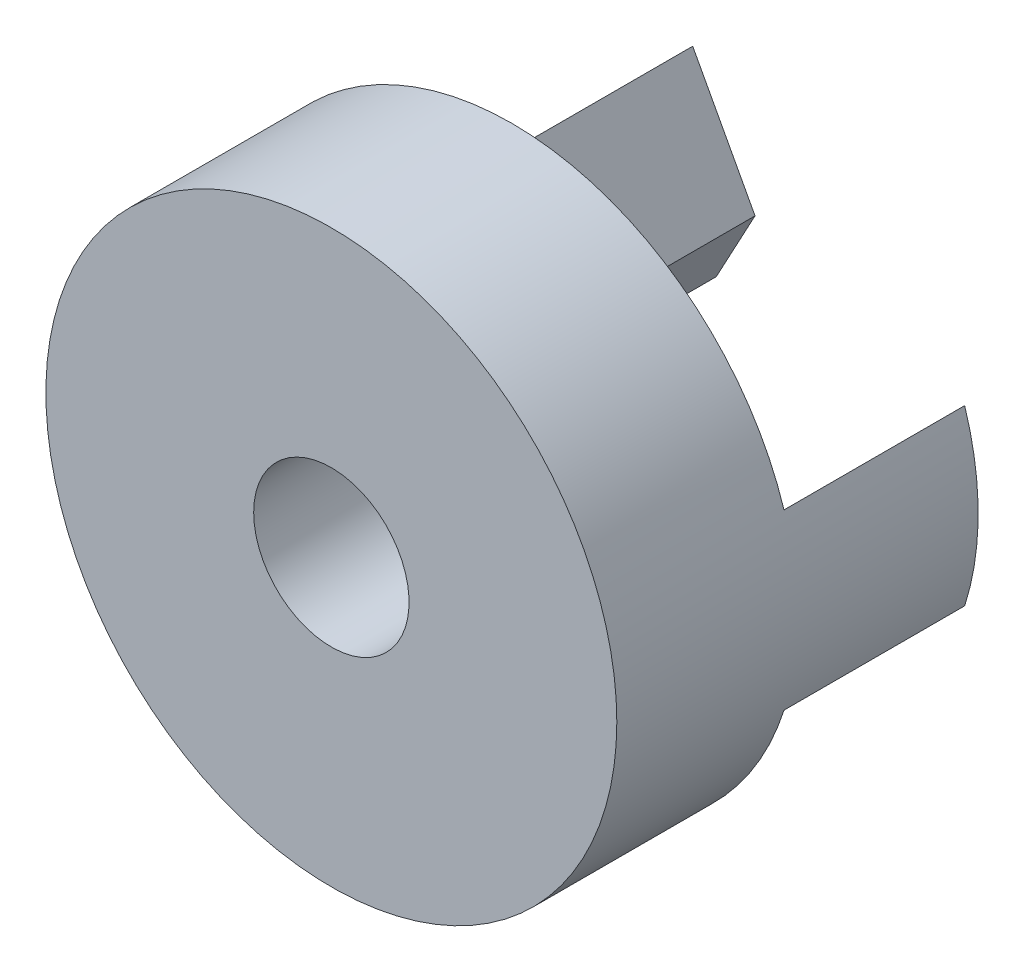
from build123d import *

# Parameters (mm, degrees)
SKETCH1_R           = 20.066
BOSS_EXTRUDE1_DEPTH = 12.7
SKETCH2_R           = 5.461
CUT_EXTRUDE1_DEPTH  = 13.7
BOSS_EXTRUDE2_DEPTH = 12.7


with BuildPart() as part:
    # Sketch1 → Boss-Extrude1 (new body)
    with BuildSketch(Plane.XY):
        Circle(SKETCH1_R)
    extrude(amount=BOSS_EXTRUDE1_DEPTH)

    # Sketch2 → Cut-Extrude1 (cut, through all)
    with BuildSketch(Plane(origin=(0, 0, 0), x_dir=(-1, 0, 0), z_dir=(0, 0, -1))):
        Circle(SKETCH2_R)
    extrude(amount=-CUT_EXTRUDE1_DEPTH, mode=Mode.SUBTRACT)

    # Sketch3 → Boss-Extrude2 (add)
    with BuildSketch(Plane(origin=(0, 0, 0), x_dir=(-1, 0, 0), z_dir=(0, 0, -1))):
        with BuildLine():
            Line((-19.117613345, -6.096), (-14.9225, 0))
            Line((-14.9225, 0), (-19.117613345, 6.096))
            ThreePointArc((-19.117613345, 6.096), (-20.066, 0), (-19.117613345, -6.096))
        make_face()
        with BuildLine():
            Line((19.117613345, 6.096), (14.9225, 0))
            Line((14.9225, 0), (19.117613345, -6.096))
            ThreePointArc((19.117613345, -6.096), (20.066, 0), (19.117613345, 6.096))
        make_face()
        with BuildLine():
            Line((0, 18.415), (-4.3815, 10.27697427))
            Line((-4.3815, 10.27697427), (-1.651, 5.205450989))
            ThreePointArc((-1.651, 5.205450989), (0, 5.461), (1.651, 5.205450989))
            Line((1.651, 5.205450989), (4.3815, 10.27697427))
            Line((4.3815, 10.27697427), (0, 18.415))
        make_face()
        with BuildLine():
            Line((-1.651, -5.205450989), (-4.3815, -10.27697427))
            Line((-4.3815, -10.27697427), (0, -18.415))
            Line((0, -18.415), (4.3815, -10.27697427))
            Line((4.3815, -10.27697427), (1.651, -5.205450989))
            ThreePointArc((1.651, -5.205450989), (0, -5.461), (-1.651, -5.205450989))
        make_face()
    extrude(amount=BOSS_EXTRUDE2_DEPTH)


solid = part.part
